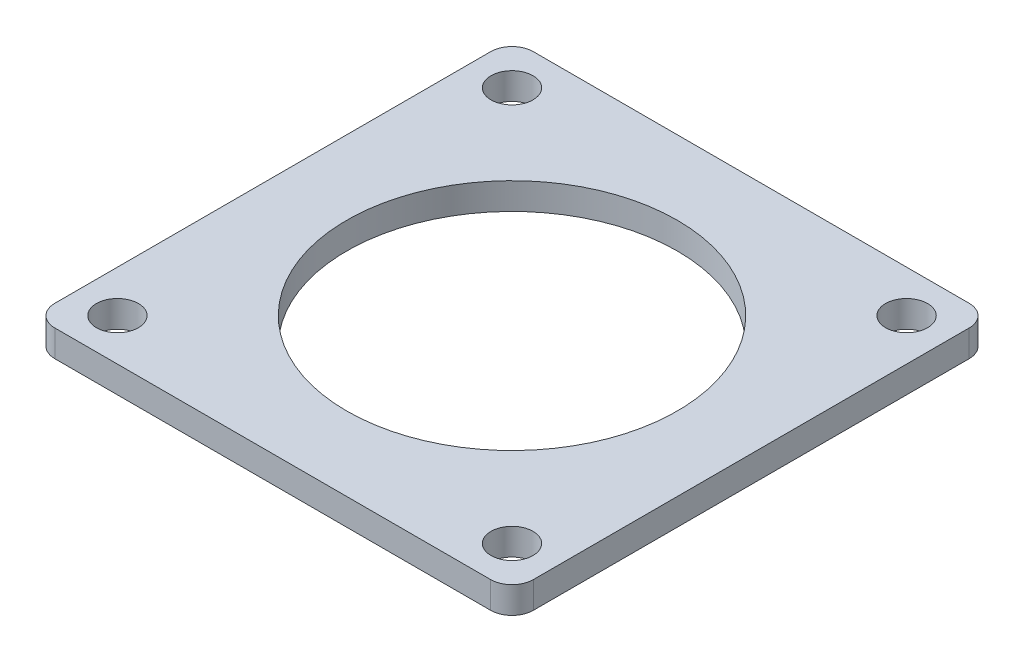
from build123d import *

# Parameters (mm, degrees)
SKETCH1_R           = 19.685
SKETCH1_R_2         = 2.499995
BOSS_EXTRUDE1_DEPTH = 3.175


with BuildPart() as part:
    # Sketch1 → Boss-Extrude1 (new body)
    with BuildSketch(Plane(origin=(0, 0, 0), x_dir=(1, 0, 0), z_dir=(0, 1, 0))):
        with BuildLine():
            Line((-13.993314597, 28.4999938), (-25.9599938, 28.4999938))
            ThreePointArc((-25.9599938, 28.4999938), (-27.756045024, 27.756045024), (-28.4999938, 25.9599938))
            Line((-28.4999938, 25.9599938), (-28.4999938, 13.993314597))
            Line((-28.4999938, 13.993314597), (-28.4999938, -13.993314597))
            Line((-28.4999938, -13.993314597), (-28.4999938, -25.9599938))
            ThreePointArc((-28.4999938, -25.9599938), (-27.756045024, -27.756045024), (-25.9599938, -28.4999938))
            Line((-25.9599938, -28.4999938), (-13.993314597, -28.4999938))
            Line((-13.993314597, -28.4999938), (13.993314597, -28.4999938))
            Line((13.993314597, -28.4999938), (25.9599938, -28.4999938))
            ThreePointArc((25.9599938, -28.4999938), (27.756045024, -27.756045024), (28.4999938, -25.9599938))
            Line((28.4999938, -25.9599938), (28.4999938, -13.993314597))
            Line((28.4999938, -13.993314597), (28.4999938, 13.993314597))
            Line((28.4999938, 13.993314597), (28.4999938, 25.9599938))
            ThreePointArc((28.4999938, 25.9599938), (27.756045024, 27.756045024), (25.9599938, 28.4999938))
            Line((25.9599938, 28.4999938), (13.993314597, 28.4999938))
            Line((13.993314597, 28.4999938), (-13.993314597, 28.4999938))
        make_face()
        Circle(SKETCH1_R, mode=Mode.SUBTRACT)
        with Locations((-23.5000038, 23.5000038)):
            Circle(SKETCH1_R_2, mode=Mode.SUBTRACT)
        with Locations((23.5000038, 23.5000038)):
            Circle(SKETCH1_R_2, mode=Mode.SUBTRACT)
        with Locations((23.5000038, -23.5000038)):
            Circle(SKETCH1_R_2, mode=Mode.SUBTRACT)
        with Locations((-23.5000038, -23.5000038)):
            Circle(SKETCH1_R_2, mode=Mode.SUBTRACT)
    extrude(amount=BOSS_EXTRUDE1_DEPTH)


solid = part.part
